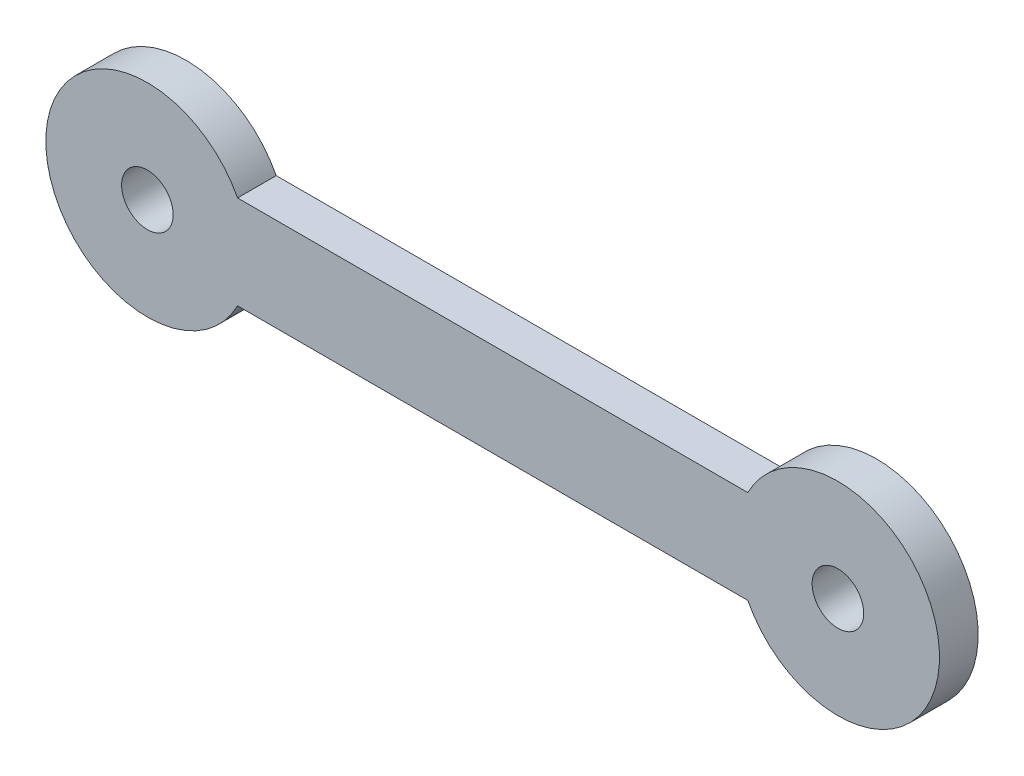
from build123d import *

# Parameters (mm, degrees)
SKETCH1_R           = 6.35
BOSS_EXTRUDE1_DEPTH = 9.525


with BuildPart() as part:
    # Sketch1 → Boss-Extrude1 (new body)
    with BuildSketch(Plane.XY):
        with BuildLine():
            Line((22.199424575, 11.49985), (147.800235425, 11.49985))
            ThreePointArc((147.800235425, 11.49985), (195.00088, 0), (147.800235425, -11.49985))
            Line((147.800235425, -11.49985), (22.199424575, -11.49985))
            ThreePointArc((22.199424575, -11.49985), (-25.00122, 0), (22.199424575, 11.49985))
        make_face()
        Circle(SKETCH1_R, mode=Mode.SUBTRACT)
        with Locations((169.99966, 0)):
            Circle(SKETCH1_R, mode=Mode.SUBTRACT)
    extrude(amount=BOSS_EXTRUDE1_DEPTH)


solid = part.part
